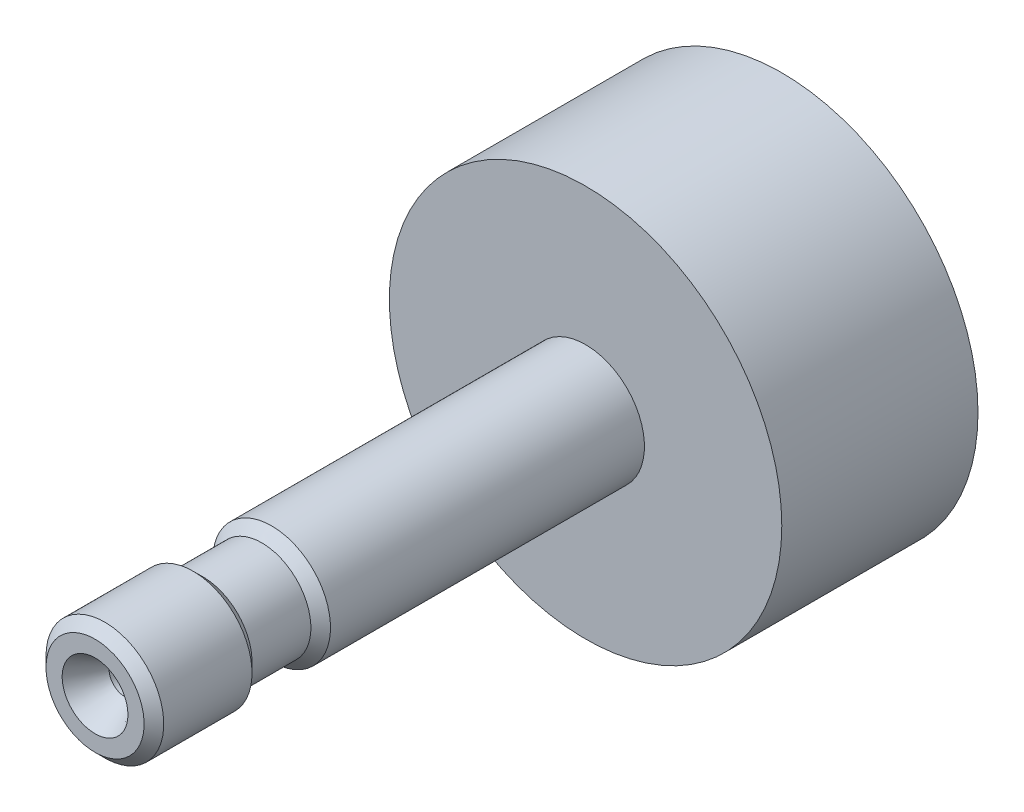
from build123d import *

# Parameters (mm, degrees)
SKIZZE1_R                                     = 10
AUFSATZ_LINEAR_BASIS_KANN_UNTERSCHIEDLI_DEPTH = 10


with BuildPart() as part:
    # Skizze1 → Aufsatz-Linear Basis (Kann unterschiedliche Formen haben) (new body)
    with BuildSketch(Plane.XY):
        Circle(SKIZZE1_R)
    extrude(amount=-AUFSATZ_LINEAR_BASIS_KANN_UNTERSCHIEDLI_DEPTH)


with BuildPart() as body_2:
    # Skizze2 → Lehrengriffstück (revolve)
    with BuildSketch(Plane(origin=(0, 0, 0), x_dir=(0, 0, -1), z_dir=(1, 0, 0)), mode=Mode.PRIVATE) as lehrengriffst_ck_sk:
        Polygon((0, 0), (0, 3), (-16, 3), (-16.5, 2.5), (-19.5, 2.5), (-20, 3), (-24.5, 3), (-25, 2.5), (-25, 0), align=None)
    revolve(lehrengriffst_ck_sk.sketch.rotate(Axis((0, 0, -0.937789373), (0, 0, 1)), 90), axis=Axis((0, 0, -0.937789373), (0, 0, 1)))  # turned: the seam where the file's is

    # Skizze3 → Schnitt-Rotation1 (revolve, cut)
    with BuildSketch(Plane(origin=(0, 0, 25), x_dir=(1, 0, 0), z_dir=(0, -1, 0)), mode=Mode.PRIVATE) as schnitt_rotation1_sk:
        Polygon((0, -3.380688495), (0.8, -2.9), (0.8, -1.515544457), (1.675, 0), (0, 0), align=None)
    revolve(schnitt_rotation1_sk.sketch.rotate(Axis((0, 0, 25), (0, 0, -1)), 180), axis=Axis((0, 0, 25), (0, 0, -1)), mode=Mode.SUBTRACT)  # turned: the seam where the file's is


solid = Compound([part.part, body_2.part])
